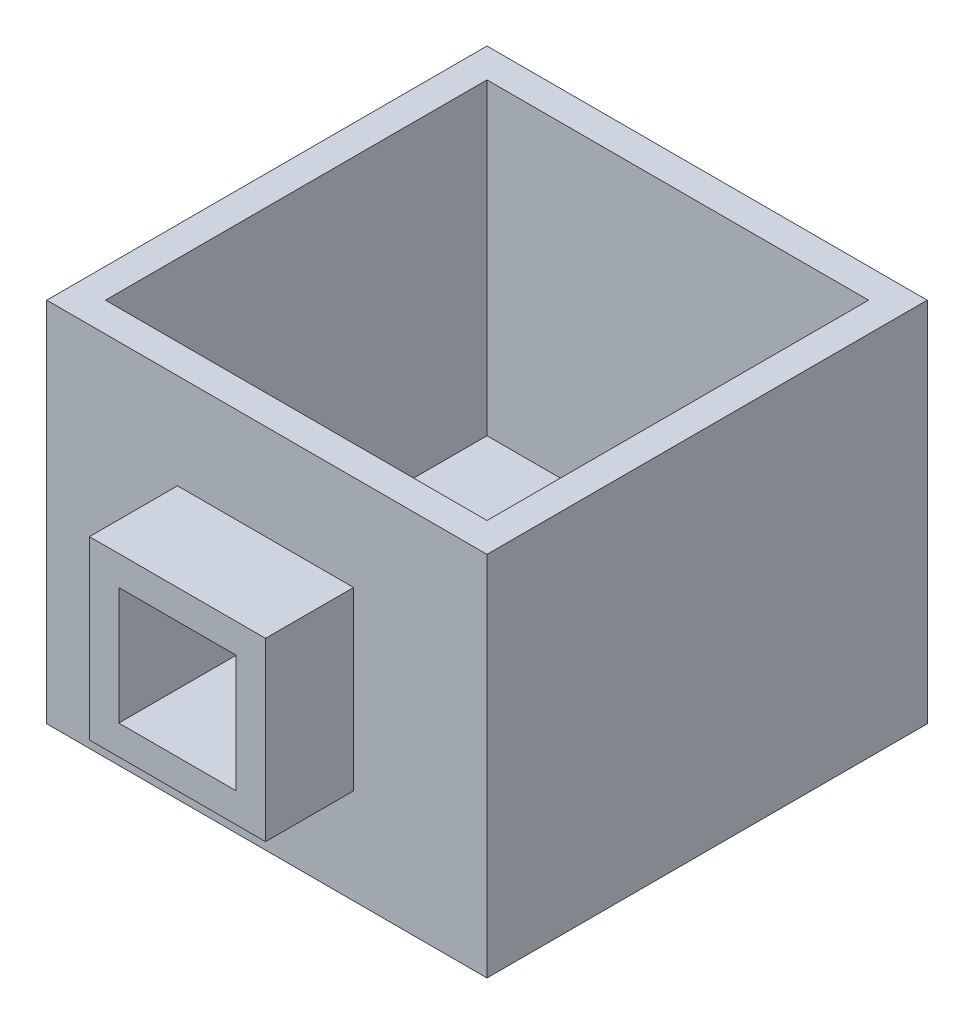
from build123d import *

# Parameters (mm, degrees)
SKETCH2_W           = 300
SKETCH2_H           = 300
BOSS_EXTRUDE1_DEPTH = 250
SKETCH4_W           = 260
SKETCH4_H           = 260
CUT_EXTRUDE2_DEPTH  = 210
SKETCH6_W           = 120
SKETCH6_H           = 120
BOSS_EXTRUDE2_DEPTH = 60
CUT_EXTRUDE7_REACH  = 362
SKETCH11_W          = 80
SKETCH11_H          = 80


with BuildPart() as part:
    # Sketch2 → Boss-Extrude1 (new body)
    with BuildSketch(Plane(origin=(0, 0, 0), x_dir=(1, 0, 0), z_dir=(0, 1, 0))):
        with Locations((150, -150)):
            Rectangle(SKETCH2_W, SKETCH2_H)
    extrude(amount=-BOSS_EXTRUDE1_DEPTH)

    # Sketch4 → Cut-Extrude2 (cut)
    with BuildSketch(Plane(origin=(0, 0, 0), x_dir=(1, 0, 0), z_dir=(0, 1, 0))):
        with Locations((150, -150)):
            Rectangle(SKETCH4_W, SKETCH4_H)
    extrude(amount=-CUT_EXTRUDE2_DEPTH, mode=Mode.SUBTRACT)

    # Sketch6 → Boss-Extrude2 (add)
    with BuildSketch(Plane.XY.offset(300)):
        with Locations((149.088747211, -125)):
            Rectangle(SKETCH6_W, SKETCH6_H)
    extrude(amount=BOSS_EXTRUDE2_DEPTH)

    # Sketch11 → Cut-Extrude7 (cut, up to next)
    with BuildSketch(Plane.XY.offset(360), mode=Mode.PRIVATE) as cut_extrude7_sk1:
        with Locations((149.088747211, -125)):
            Rectangle(SKETCH11_W, SKETCH11_H)
    cut_extrude7_tool1 = extrude(cut_extrude7_sk1.sketch, amount=-CUT_EXTRUDE7_REACH, mode=Mode.PRIVATE) & part.part
    add(cut_extrude7_tool1.solids().sort_by_distance((149.088747, -125, 360))[0], mode=Mode.SUBTRACT)


solid = part.part
